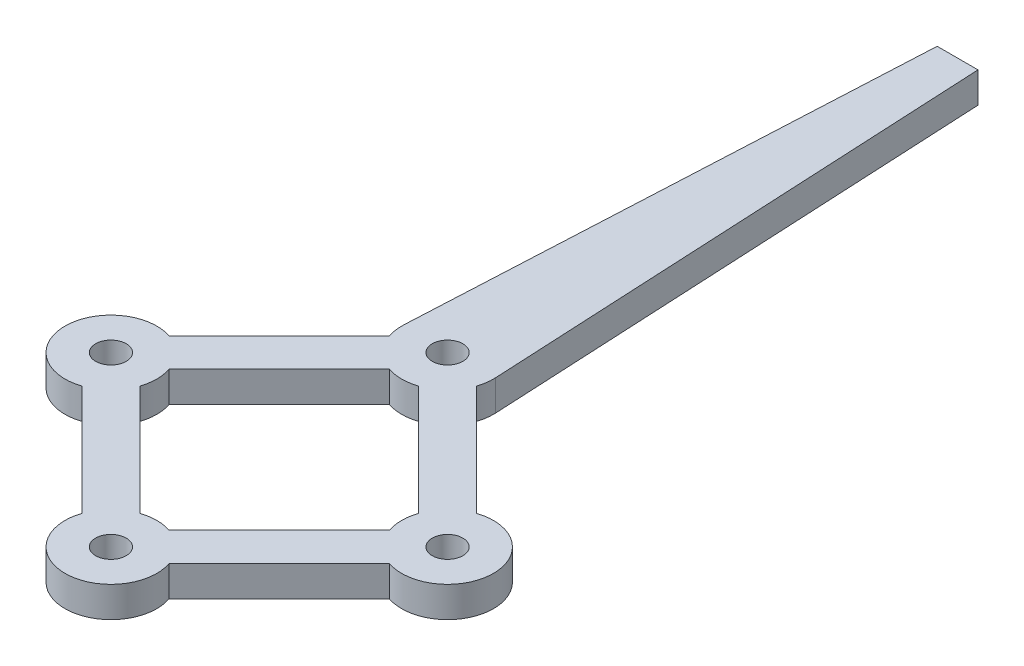
from build123d import *

# Parameters (mm, degrees)
SKETCH1_R           = 1.5
BOSS_EXTRUDE1_DEPTH = 3


with BuildPart() as part:
    # Sketch1 → Boss-Extrude1 (new body)
    with BuildSketch(Plane(origin=(0, 0, 0), x_dir=(1, 0, 0), z_dir=(0, 1, 0))):
        with BuildLine():
            Line((-2, 83), (2, 83))
            Line((2, 83), (4.494360181, 33.225225593))
            ThreePointArc((4.494360181, 33.225225593), (4.457597858, 32.38370353), (4.264652125, 31.563775))
            Line((4.264652125, 31.563775), (15.063775, 20.764652125))
            ThreePointArc((15.063775, 20.764652125), (21, 16.5), (15.063775, 12.235347875))
            Line((15.063775, 12.235347875), (4.264652125, 1.436225))
            ThreePointArc((4.264652125, 1.436225), (0, -4.5), (-4.264652125, 1.436225))
            Line((-4.264652125, 1.436225), (-15.063775, 12.235347875))
            ThreePointArc((-15.063775, 12.235347875), (-21, 16.5), (-15.063775, 20.764652125))
            Line((-15.063775, 20.764652125), (-4.264652125, 31.563775))
            ThreePointArc((-4.264652125, 31.563775), (-4.454454203, 32.361378239), (-4.496391332, 33.180180433))
            Line((-4.496391332, 33.180180433), (-2, 83))
        make_face()
        Circle(SKETCH1_R, mode=Mode.SUBTRACT)
        with Locations((0, 33)):
            Circle(SKETCH1_R, mode=Mode.SUBTRACT)
        with Locations((-16.5, 16.5)):
            Circle(SKETCH1_R, mode=Mode.SUBTRACT)
        with Locations((16.5, 16.5)):
            Circle(SKETCH1_R, mode=Mode.SUBTRACT)
        with BuildLine():
            Line((12.235347875, 17.936225), (1.436225, 28.735347875))
            ThreePointArc((1.436225, 28.735347875), (0, 28.5), (-1.436225, 28.735347875))
            Line((-1.436225, 28.735347875), (-12.235347875, 17.936225))
            ThreePointArc((-12.235347875, 17.936225), (-12, 16.5), (-12.235347875, 15.063775))
            Line((-12.235347875, 15.063775), (-1.436225, 4.264652125))
            ThreePointArc((-1.436225, 4.264652125), (0, 4.5), (1.436225, 4.264652125))
            Line((1.436225, 4.264652125), (12.235347875, 15.063775))
            ThreePointArc((12.235347875, 15.063775), (12, 16.5), (12.235347875, 17.936225))
        make_face(mode=Mode.SUBTRACT)
    extrude(amount=BOSS_EXTRUDE1_DEPTH)


solid = part.part
